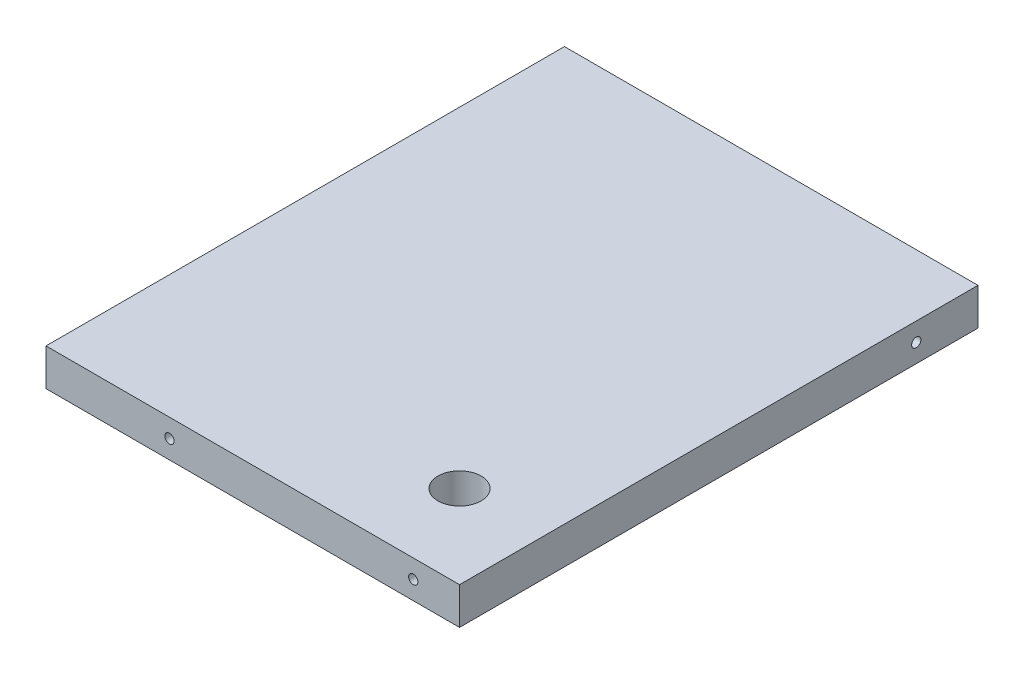
from build123d import *

# Parameters (mm, degrees)
SKETCH1_W           = 134
SKETCH1_H           = 168
SKETCH1_R           = 7
BOSS_EXTRUDE1_DEPTH = 12
CUT_EXTRUDE1_START  = -44.256673
SKETCH2_R           = 1.5
CUT_EXTRUDE1_DEPTH  = 20
CUT_EXTRUDE2_START  = -20.894163
SKETCH3_R           = 1.5
CUT_EXTRUDE2_DEPTH  = 20


with BuildPart() as part:
    # Sketch1 → Boss-Extrude1 (new body)
    with BuildSketch(Plane(origin=(0, 0, 0), x_dir=(1, 0, 0), z_dir=(0, 1, 0))):
        with Locations((-87.894163325, 128.256672781)):
            Rectangle(SKETCH1_W, SKETCH1_H)
        with Locations((-47.894163325, 71.256672781)):
            Circle(SKETCH1_R, mode=Mode.SUBTRACT)
    extrude(amount=BOSS_EXTRUDE1_DEPTH)

    # Sketch2 → Cut-Extrude1 (cut)
    with BuildSketch(Plane.XY.offset(CUT_EXTRUDE1_START)):
        with Locations((-114.894163325, 6)):
            Circle(SKETCH2_R)
        with Locations((-35.894163325, 6)):
            Circle(SKETCH2_R)
    extrude(amount=-CUT_EXTRUDE1_DEPTH, mode=Mode.SUBTRACT)

    # Sketch3 → Cut-Extrude2 (cut)
    with BuildSketch(Plane(origin=(0, 0, 0), x_dir=(0, 0, -1), z_dir=(1, 0, 0)).offset(CUT_EXTRUDE2_START)):
        with Locations((192.256672781, 6)):
            Circle(SKETCH3_R)
    extrude(amount=-CUT_EXTRUDE2_DEPTH, mode=Mode.SUBTRACT)


solid = part.part
